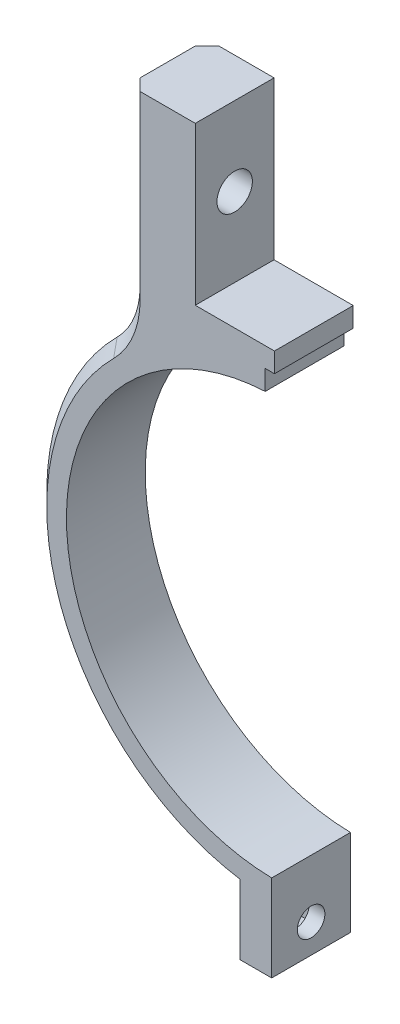
from build123d import *

# Parameters (mm, degrees)
AUFSATZ_LINEAR_AUSTRAGEN1_DEPTH = 10
SKIZZE2_R                       = 1.75
SCHNITT_LINEAR_AUSTRAGEN1_DEPTH = 36.05
SKIZZE4_R                       = 2.25
SCHNITT_LINEAR_AUSTRAGEN3_DEPTH = 50.25
VERRUNDUNG1_R                   = 10
SKIZZE5_W                       = 5.55
SKIZZE5_H                       = 5.55
SCHNITT_LINEAR_AUSTRAGEN4_DEPTH = 2
SCHNITT_LINEAR_AUSTRAGEN5_DEPTH = 11
FASE1_SIZE                      = 1.5
SCHNITT_LINEAR_AUSTRAGEN6_DEPTH = 11


with BuildPart() as part:
    # Skizze1 → Aufsatz-Linear austragen1 (new body)
    with BuildSketch(Plane.XY):
        with BuildLine():
            Line((0.5, -26.545291485), (0.5, -30.545908073))
            Line((0.5, -30.545908073), (0.5, -37.545908073))
            Line((0.5, -37.545908073), (4.5, -37.545908073))
            Line((4.5, -37.545908073), (4.5, -30.216758595))
            ThreePointArc((4.5, -30.216758595), (29.558680329, -7.719256261), (18.7, 24.158073185))
            Line((18.7, 24.158073185), (18.7, 51.55))
            Line((18.7, 51.55), (10.2, 51.55))
            Line((10.2, 51.55), (10.2, 31.55))
            Line((10.2, 31.55), (-10.2, 31.55))
            Line((-10.2, 31.55), (-10.2, 51.55))
            Line((-10.2, 51.55), (-18.7, 51.55))
            Line((-18.7, 51.55), (-18.7, 24.158073185))
            ThreePointArc((-18.7, 24.158073185), (-29.558680329, -7.719256261), (-4.5, -30.216758595))
            Line((-4.5, -30.216758595), (-4.5, -37.545908073))
            Line((-4.5, -37.545908073), (-0.5, -37.545908073))
            Line((-0.5, -37.545908073), (-0.5, -30.545908073))
            Line((-0.5, -30.545908073), (-0.5, -26.545291485))
            ThreePointArc((-0.5, -26.545291485), (0, 26.55), (0.5, -26.545291485))
        make_face()
    extrude(amount=AUFSATZ_LINEAR_AUSTRAGEN1_DEPTH)

    # Skizze2 → Schnitt-Linear austragen1 (cut, through all)
    with BuildSketch(Plane.ZY.offset(4.5)):
        with Locations((5, -33.881333334)):
            Circle(SKIZZE2_R)
    extrude(amount=-SCHNITT_LINEAR_AUSTRAGEN1_DEPTH, mode=Mode.SUBTRACT)

    # Skizze4 → Schnitt-Linear austragen3 (cut, through all)
    with BuildSketch(Plane.ZY.offset(18.7)):
        with Locations((5, 41.55)):
            Circle(SKIZZE4_R)
    extrude(amount=-SCHNITT_LINEAR_AUSTRAGEN3_DEPTH, mode=Mode.SUBTRACT)

    # Verrundung1
    verrundung1_edges = [part.edges().sort_by_distance(p)[0] for p in [
        (-18.7, 24.158073185, 5),
        (18.7, 24.158073185, 5),
    ]]
    fillet(verrundung1_edges, radius=VERRUNDUNG1_R)

    # Skizze5 → Schnitt-Linear austragen4 (cut)
    with BuildSketch(Plane.ZY.offset(4.5)):
        with Locations((5, -33.881333334)):
            Rectangle(SKIZZE5_W, SKIZZE5_H)
    extrude(amount=-SCHNITT_LINEAR_AUSTRAGEN4_DEPTH, mode=Mode.SUBTRACT)

    # Skizze6 → Schnitt-Linear austragen5 (cut, through all)
    with BuildSketch(Plane.XY):
        Polygon((0, 0), (0, 63.91348789), (40.013946788, 63.91348789), (48.360414216, -54.819102682), (0, -54.819102682), align=None)
    extrude(amount=SCHNITT_LINEAR_AUSTRAGEN5_DEPTH, mode=Mode.SUBTRACT)

    # Fase1
    fase1_edges = [part.edges().sort_by_distance(p)[0] for p in [
        (-18.7, 40.098167422, 0),
        (-18.7, 40.098167422, 10),
        (-29.006358008, -9.588206043, 0),
        (-29.006358008, -9.588206043, 10),
        (-19.459415096, 24.823823807, 0),
        (-19.459415096, 24.823823807, 10),
    ]]
    chamfer(fase1_edges, length=FASE1_SIZE)

    # Skizze7 → Schnitt-Linear austragen6 (cut, through all)
    with BuildSketch(Plane.XY.offset(10)):
        Polygon((1.325, 29.05), (0, 29.05), (0, 31.55), (-0.15, 31.55), (-0.15, 29.05), (-1.325, 29.05), (-1.325, 23.522445011), (1.325, 23.522445011), align=None)
    extrude(amount=-SCHNITT_LINEAR_AUSTRAGEN6_DEPTH, mode=Mode.SUBTRACT)


solid = part.part
